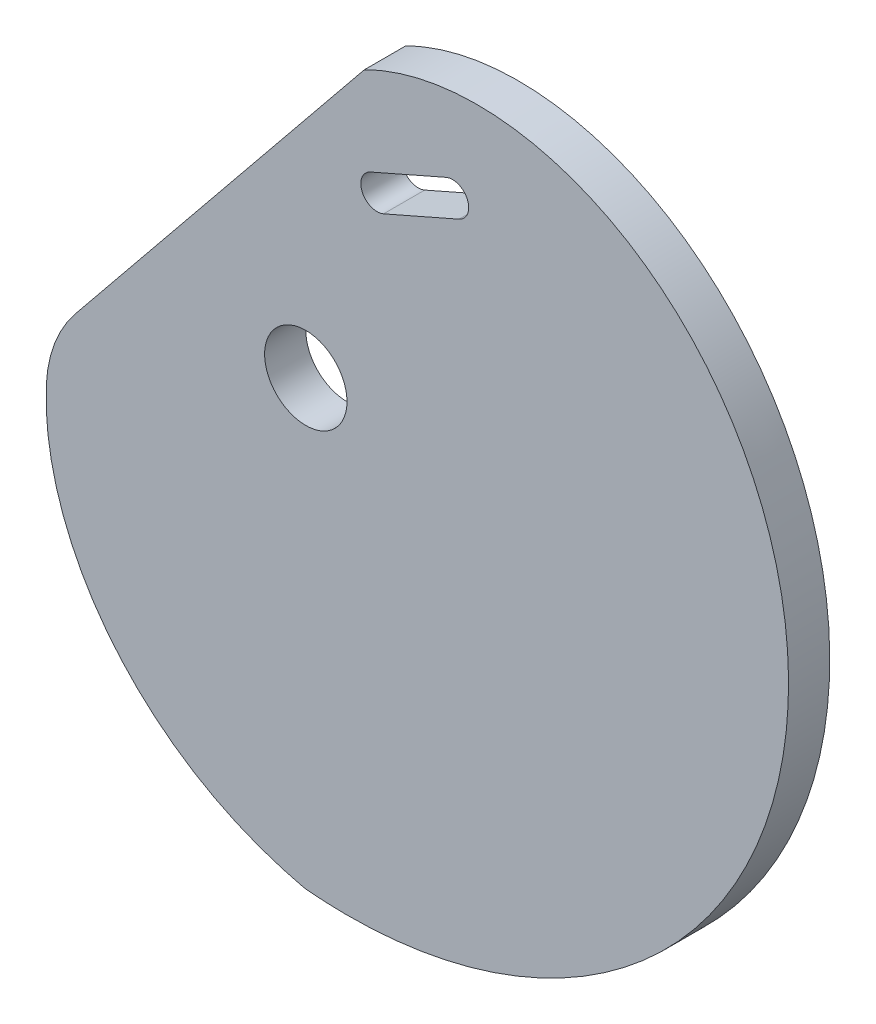
from build123d import *

# Parameters (mm, degrees)
SKETCH1_R               = 6.35
BOSS_EXTRUDE1_DEPTH     = 3.175
CUT_EXTRUDE1_DEPTH      = 102.208623711
CUT_EXTRUDE1_DEPTH_BACK = 102.208623711
FILLET1_R               = 20


with BuildPart() as part:
    # Sketch1 → Boss-Extrude1 (new, symmetric)
    with BuildSketch(Plane.XY):
        with BuildLine():
            add(Edge.make_bspline(
                [(0, -68.230921715), (0.393333706, -68.291733321), (1.194961176, -68.321276753), (2.388868431, -68.414811628), (3.58891617, -68.470136134), (4.791044831, -68.510535556), (5.995946289, -68.52954927), (7.203026535, -68.528713614), (8.412027616, -68.507423129), (9.62259203, -68.465654591), (10.83437986, -68.403235569), (12.047037443, -68.320041284), (13.260205927, -68.215942066), (14.473519127, -68.090817818), (15.686604264, -67.944554476), (16.899081946, -67.777045295), (18.110566359, -67.588190842), (19.320665416, -67.377899329), (20.528980925, -67.146086849), (21.73510877, -66.892677633), (22.938639087, -66.6176043), (24.139156466, -66.320808097), (25.336240146, -66.002239142), (26.529464226, -65.661856654), (27.718397887, -65.299629187), (28.90260561, -64.915534847), (30.081647414, -64.509561514), (31.255079097, -64.081707052), (32.42245248, -63.631979515), (33.58331567, -63.160397343), (34.737213315, -62.666989561), (35.883686879, -62.151795956), (37.022274916, -61.614867262), (38.152513354, -61.056265327), (39.273935784, -60.476063279), (40.386073758, -59.87434568), (41.488457085, -59.251208675), (42.580614147, -58.606760131), (43.662072205, -57.941119771), (44.732357722, -57.254419292), (45.790996682, -56.546802486), (46.837514925, -55.81842534), (47.871438475, -55.069456136), (48.89229388, -54.300075538), (49.899608554, -53.51047667), (50.892911122, -52.700865183), (51.871731772, -51.87145932), (52.835602603, -51.022489959), (53.784057989, -50.154200657), (54.71663493, -49.26684768), (55.632873421, -48.360700021), (56.532316811, -47.436039411), (57.414512174, -46.493160317), (58.279010671, -45.532369935), (59.125367928, -44.553988165), (59.953144401, -43.558347582), (60.761905749, -42.545793391), (61.55122321, -41.516683378), (62.320673971, -40.471387842), (63.069841543, -39.410289525), (63.798316132, -38.333783527), (64.505695017, -37.242277204), (65.191582915, -36.13619007), (65.85559236, -35.015953676), (66.497344063, -33.882011479), (67.11646729, -32.734818707), (67.71260022, -31.574842209), (68.285390316, -30.402560293), (68.834494677, -29.218462553), (69.359580408, -28.023049692), (69.860324965, -26.816833323), (70.336416512, -25.60033577), (70.787554269, -24.374089852), (71.213448854, -23.13863866), (71.613822626, -21.894535318), (71.988410015, -20.642342743), (72.336957858, -19.382633384), (72.659225719, -18.115988959), (72.954986211, -16.843000179), (73.224025309, -15.564266461), (73.466142659, -14.28039563), (73.681151874, -12.992003617), (73.868880836, -11.699714142), (74.029171977, -10.404158388), (74.161882563, -9.10597467), (74.266884966, -7.805808087), (74.344066927, -6.504310174), (74.393331816, -5.202138538), (74.414598879, -3.89995649), (74.407803478, -2.598432666), (74.372897323, -1.29824064), (74.309848696, -5.853e-05), (74.218642658, 1.295431404), (74.099281259, 2.587543173), (73.95178373, 3.875587471), (73.776186663, 5.158872107), (73.572544188, 6.43670243), (73.340928136, 7.708381771), (73.081428188, 8.973211889), (72.794152019, 10.230493418), (72.47922543, 11.479526328), (72.13679246, 12.719610386), (71.767015501, 13.950045625), (71.37007539, 15.170132817), (70.946171493, 16.379173951), (70.495521777, 17.576472716), (70.018362872, 18.761334989), (69.514950114, 19.933069325), (68.985557583, 21.090987453), (68.430478125, 22.234404772), (67.850023359, 23.362640855), (67.244523678, 24.47501995), (66.614328227, 25.570871489), (65.959804877, 26.649530597), (65.281340181, 27.710338599), (64.579339317, 28.752643533), (63.85422602, 29.775800665), (63.106442497, 30.779173), (62.33644933, 31.762131799), (61.544725366, 32.724057086), (60.731767601, 33.66433818), (59.898090995, 34.582374149), (59.044228508, 35.477574541), (58.170730235, 36.349359075), (57.278166357, 37.197160694), (56.367121668, 38.020410915), (55.438270074, 38.818621759), (54.492318121, 39.591335254), (53.529982536, 40.3381068), (52.551992493, 41.058512637), (51.559087829, 41.752148676), (50.552018856, 42.418631155), (49.531545735, 43.057596786), (48.498437965, 43.668703015), (47.453473832, 44.251628246), (46.397439863, 44.806072049), (45.331130274, 45.331755356), (44.255346411, 45.828420647), (43.17089619, 46.295832116), (42.078593533, 46.733775825), (40.979257798, 47.142059848), (39.873713209, 47.520514394), (38.762788284, 47.868991924), (37.647315256, 48.187367242), (36.528129497, 48.475537585), (35.406068937, 48.733422689), (34.281973488, 48.960964845), (33.156684455, 49.158128938), (32.031043959, 49.324902476), (30.905894352, 49.461295599), (29.78207764, 49.567341079), (28.66043489, 49.643094299), (27.541805663, 49.688633226), (26.427027423, 49.704058363), (25.316934962, 49.689492689), (24.212359828, 49.645081585), (23.114129743, 49.570992746), (22.023068037, 49.46741608), (20.939993076, 49.334563587), (19.865717696, 49.172669234), (18.801048645, 48.981988806), (17.746786017, 48.762799751), (16.703722704, 48.515401007), (15.672643843, 48.240112817), (14.654326272, 47.93727653), (13.64953799, 47.607254389), (12.659037622, 47.250429307), (11.683573889, 46.867204624), (10.723885088, 46.458003864), (9.780698574, 46.023270462), (8.85473025, 45.563467495), (7.946684063, 45.079077388), (7.057251515, 44.570601617), (6.187111156, 44.038560382), (5.336928158, 43.48349234), (4.507353656, 42.905954051), (3.699024971, 42.306520427), (2.912619563, 41.685826384), (2.149082762, 41.044776761), (1.408732666, 40.385653153), (0.69201842, 39.710962437), (-0.000702823, 39.023274092), (-0.669224606, 38.325164066), (-1.313490613, 37.619209289), (-1.933594741, 36.907981167), (-2.529780734, 36.194039342), (-3.102441662, 35.479925366), (-3.652119172, 34.768156406), (-4.179502537, 34.061218936), (-4.68542751, 33.361562432), (-5.170874981, 32.671593072), (-5.636969475, 31.993667421), (-6.084977486, 31.330086125), (-6.5163057, 30.68308757), (-6.932499191, 30.054841594), (-7.335239472, 29.447442991), (-7.726343211, 28.862905788), (-8.107759261, 28.30315506), (-8.481572996, 27.770028153), (-8.850055929, 27.265150233), (-9.21599154, 26.789707359), (-9.58007402, 26.342396401), (-9.943199031, 25.921274986), (-10.306211946, 25.524302901), (-10.669815304, 25.149428396), (-11.03457423, 24.794597749), (-11.400917427, 24.457759077), (-11.769139802, 24.136868148), (-12.139404915, 23.829894257), (-12.511747444, 23.534826559), (-12.886075425, 23.249680558), (-13.262172288, 22.972504592), (-13.639698706, 22.701386132), (-14.018194373, 22.4344578), (-14.397079826, 22.169903041), (-14.775658393, 21.905961469), (-15.153118349, 21.640933911), (-15.528535328, 21.37318718), (-15.900874865, 21.101158728), (-16.268995598, 20.823360748), (-16.631651048, 20.538385549), (-16.987497448, 20.244905703), (-17.335071725, 19.941700072), (-17.674482118, 19.629485326), (-18.005889299, 19.308945872), (-18.329486913, 18.98074786), (-18.645506177, 18.6455329), (-18.954213469, 18.303917657), (-19.255909475, 17.956492143), (-19.550927855, 17.603818409), (-19.839633983, 17.246429189), (-20.122423608, 16.884826615), (-20.39972148, 16.519480973), (-20.671979932, 16.15082951), (-20.93967742, 15.77927529), (-21.203317027, 15.405186109), (-21.463424922, 15.028893458), (-21.720548787, 14.650691546), (-21.975256201, 14.270836377), (-22.228133, 13.889544888), (-22.479781587, 13.506994147), (-22.730819224, 13.123320602), (-22.981876279, 12.738619403), (-23.233594452, 12.35294377), (-23.486624965, 11.966304432), (-23.741626724, 11.578669117), (-23.999264462, 11.189962103), (-24.260206854, 10.800063825), (-24.52512461, 10.408810538), (-24.794688561, 10.015994037), (-25.069567717, 9.621361426), (-25.350427363, 9.224614974), (-25.637926993, 8.8254119), (-25.932718851, 8.423364715), (-26.235444149, 8.018039723), (-26.546738212, 7.608962846), (-26.867193334, 7.195608336), (-27.197393741, 6.777566684), (-27.537037782, 6.353934602), (-27.885559202, 5.923803469), (-28.242374703, 5.486366009), (-28.606855737, 5.040842301), (-28.978345064, 4.586492757), (-29.356154138, 4.122615768), (-29.739565815, 3.648549546), (-30.127835637, 3.163672741), (-30.520193566, 2.667405334), (-30.915845631, 2.159209384), (-31.313975642, 1.638589743), (-31.713746908, 1.10509472), (-32.114303997, 0.558316687), (-32.514774496, -0.002107372), (-32.914270801, -0.576495363), (-33.311891916, -1.165119646), (-33.70672526, -1.768206653), (-34.097848491, -2.385936568), (-34.484331334, -3.01844306), (-34.865237414, -3.665813085), (-35.239626095, -4.328086735), (-35.606554319, -5.00525716), (-35.965078448, -5.697270543), (-36.314256102, -6.404026134), (-36.653147994, -7.125376348), (-36.98081976, -7.861126926), (-37.296343783, -8.611037148), (-37.598801011, -9.374820113), (-37.887282738, -10.15214308), (-38.160892488, -10.942627847), (-38.418747446, -11.745851279), (-38.659981522, -12.561345551), (-38.883742182, -13.388599746), (-39.089211497, -14.227059816), (-39.27554787, -15.076191303), (-39.442240692, -15.935443066), (-39.58900499, -16.804297383), (-39.715531283, -17.682274795), (-39.821534024, -18.56888584), (-39.906736403, -19.463633732), (-39.970874682, -20.366013757), (-40.01369729, -21.27551381), (-40.034965324, -22.191614638), (-40.034452659, -23.113790166), (-40.011946156, -24.041507803), (-39.967245835, -24.974228766), (-39.900165044, -25.911408403), (-39.810530622, -26.852496518), (-39.698183052, -27.796937709), (-39.56297661, -28.744171699), (-39.4047795, -29.693633681), (-39.223473982, -30.64475466), (-39.018956498, -31.596961802), (-38.791137779, -32.549678783), (-38.539942955, -33.502326148), (-38.265311644, -34.454321664), (-37.967198044, -35.405080681), (-37.645571006, -36.354016496), (-37.300414107, -37.300540716), (-36.931725709, -38.244063627), (-36.539519007, -39.18399456), (-36.123822074, -40.119742265), (-35.684677893, -41.050715279), (-35.222144381, -41.976322302), (-34.736294403, -42.89597257), (-34.227215775, -43.809076229), (-33.695011264, -44.715044715), (-33.139798572, -45.613291121), (-32.561710315, -46.503230581), (-31.960893988, -47.384280643), (-31.337511928, -48.255861642), (-30.69174126, -49.117397078), (-30.023773839, -49.96831399), (-29.333816181, -50.808043326), (-28.622089382, -51.636020317), (-27.888829033, -52.451684847), (-27.134285123, -53.25448182), (-26.358721931, -54.04386153), (-25.562417912, -54.819280022), (-24.745665571, -55.580199454), (-23.908771332, -56.326088459), (-23.052055394, -57.0564225), (-22.175851579, -57.770684224), (-21.280507172, -58.468363812), (-20.366382752, -59.148959324), (-19.433852012, -59.811977048), (-18.483301577, -60.456931829), (-17.515130802, -61.083347415), (-16.529751575, -61.690756781), (-15.527588097, -62.278702456), (-14.50907667, -62.846736843), (-13.474665463, -63.39442255), (-12.424814268, -63.921332635), (-11.359994294, -64.427051169), (-10.280687768, -64.911172569), (-9.187388219, -65.373305515), (-8.080598179, -65.813059652), (-6.960836498, -66.230096831), (-5.828609627, -66.623940268), (-4.684517934, -66.994691537), (-3.528855652, -67.340343195), (-2.3631095, -67.666856553), (-1.184338477, -67.950378607), (-0.400093515, -68.169065005), (0, -68.230921715)],
                knots=[0, 0, 0, 0, 0.003319606, 0.00664483, 0.00997572, 0.013312315, 0.016654652, 0.020002764, 0.023356679, 0.026716422, 0.030082012, 0.033453467, 0.036830797, 0.040214011, 0.043603114, 0.046998106, 0.050398984, 0.05380574, 0.057218364, 0.060636841, 0.064061153, 0.067491279, 0.070927192, 0.074368865, 0.077816264, 0.081269354, 0.084728096, 0.088192446, 0.09166236, 0.095137787, 0.098618675, 0.102104968, 0.105596607, 0.10909353, 0.112595671, 0.116102963, 0.119615332, 0.123132706, 0.126655005, 0.130182149, 0.133714056, 0.137250637, 0.140791804, 0.144337465, 0.147887524, 0.151441884, 0.155000443, 0.158563099, 0.162129745, 0.165700272, 0.169274569, 0.172852522, 0.176434014, 0.180018926, 0.183607137, 0.187198521, 0.190792953, 0.194390304, 0.197990441, 0.201593231, 0.205198539, 0.208806224, 0.212416148, 0.216028167, 0.219642135, 0.223257906, 0.226875331, 0.230494258, 0.234114533, 0.237736001, 0.241358506, 0.244981886, 0.248605983, 0.252230632, 0.255855669, 0.259480928, 0.263106241, 0.266731437, 0.270356345, 0.273980794, 0.277604607, 0.281227611, 0.284849627, 0.288470478, 0.292089983, 0.295707963, 0.299324234, 0.302938615, 0.306550921, 0.310160967, 0.313768569, 0.317373538, 0.320975689, 0.324574833, 0.328170782, 0.331763348, 0.335352341, 0.338937573, 0.342518853, 0.346095993, 0.349668803, 0.353237093, 0.356800674, 0.360359359, 0.363912958, 0.367461284, 0.37100415, 0.37454137, 0.37807276, 0.381598135, 0.385117313, 0.388630113, 0.392136355, 0.395635862, 0.399128458, 0.402613969, 0.406092224, 0.409563054, 0.413026294, 0.416481778, 0.419929348, 0.423368847, 0.426800121, 0.43022302, 0.4336374, 0.437043112, 0.440439966, 0.443827754, 0.447206268, 0.450575308, 0.453934675, 0.457284173, 0.460623612, 0.463952804, 0.467271567, 0.470579721, 0.473877092, 0.477163509, 0.480438807, 0.483702825, 0.486955407, 0.490196401, 0.493425661, 0.496643048, 0.499848424, 0.50304166, 0.506222633, 0.509391223, 0.512547319, 0.515690814, 0.518821608, 0.521939609, 0.52504473, 0.528136891, 0.531216019, 0.53428205, 0.537334925, 0.540374595, 0.543401017, 0.546414157, 0.549413988, 0.552400493, 0.555373664, 0.5583335, 0.56128001, 0.564213213, 0.567133138, 0.570039821, 0.572933311, 0.575813665, 0.578680954, 0.581535256, 0.58437666, 0.58720527, 0.590021199, 0.59282457, 0.59561552, 0.598394199, 0.601160164, 0.603910525, 0.606641733, 0.609350191, 0.612032273, 0.614684334, 0.617302722, 0.619883791, 0.622423916, 0.624919509, 0.627367038, 0.629763043, 0.632104166, 0.634387177, 0.636609005, 0.638766786, 0.640857908, 0.642880081, 0.644831406, 0.646710483, 0.648516525, 0.650249514, 0.65191136, 0.653508519, 0.655048349, 0.65653798, 0.657984241, 0.659393583, 0.66077201, 0.662125022, 0.663457568, 0.664774018, 0.666078151, 0.667373165, 0.668661696, 0.669945853, 0.671227263, 0.672507127, 0.673786273, 0.67506522, 0.676344239, 0.677623416, 0.678902717, 0.68018205, 0.681461324, 0.682740438, 0.684019262, 0.685297659, 0.686575488, 0.687852615, 0.689128915, 0.690404281, 0.691678632, 0.692951916, 0.694224122, 0.695495279, 0.696765474, 0.698034846, 0.699303605, 0.70057203, 0.70184048, 0.703109399, 0.704379325, 0.705650892, 0.706924838, 0.708202013, 0.709483377, 0.710770009, 0.712063109, 0.713363997, 0.714674119, 0.715995039, 0.717328447, 0.718676146, 0.720040056, 0.721422204, 0.722824718, 0.724249822, 0.725699824, 0.727177002, 0.72868281, 0.730218172, 0.731783831, 0.733380363, 0.735008197, 0.736667628, 0.738358831, 0.740081872, 0.741836722, 0.743623264, 0.745441305, 0.747290584, 0.749170776, 0.751081502, 0.753022336, 0.754992805, 0.756992401, 0.759020578, 0.761076761, 0.763160347, 0.76527071, 0.767407202, 0.769569155, 0.771755887, 0.7739667, 0.776200882, 0.778457713, 0.780736462, 0.783036392, 0.785356757, 0.787696808, 0.790055792, 0.792432952, 0.794827532, 0.797238799, 0.799666426, 0.802110394, 0.804570687, 0.807047284, 0.809540165, 0.812049305, 0.814574675, 0.817116246, 0.819673984, 0.822247852, 0.824837811, 0.82744382, 0.830065834, 0.832703806, 0.835357687, 0.838027424, 0.840712962, 0.843414244, 0.84613121, 0.848863798, 0.851611942, 0.854375576, 0.857154631, 0.859949033, 0.862758708, 0.865583582, 0.868423573, 0.871278601, 0.874148584, 0.877033434, 0.879933066, 0.882847387, 0.885776307, 0.888719732, 0.891677564, 0.894649707, 0.897636058, 0.900636516, 0.903650977, 0.906679333, 0.909721476, 0.912777297, 0.915846682, 0.918929518, 0.922025687, 0.925135072, 0.928257554, 0.931393009, 0.934541315, 0.937702347, 0.940875975, 0.944062073, 0.947260508, 0.950471149, 0.95369386, 0.956928506, 0.960174949, 0.96343305, 0.966702667, 0.969983657, 0.973275876, 0.976579178, 0.979893415, 0.983218438, 0.986554095, 0.989900235, 0.993256703, 0.996623344, 1, 1, 1, 1], degree=3))
        make_face()
        Circle(SKETCH1_R, mode=Mode.SUBTRACT)
        with BuildLine():
            Line((9.976048944, 32.474429955), (21.605937727, 37.576947657))
            ThreePointArc((21.605937727, 37.576947657), (24.899718531, 36.29203209), (23.614802964, 32.998251286))
            Line((23.614802964, 32.998251286), (11.984914181, 27.895733584))
            ThreePointArc((11.984914181, 27.895733584), (8.691133377, 29.180649151), (9.976048944, 32.474429955))
        make_face(mode=Mode.SUBTRACT)
    extrude(amount=BOSS_EXTRUDE1_DEPTH, both=True)

    # Sketch2 → Cut-Extrude1 (cut, two sides)
    with BuildSketch(Plane.XY) as cut_extrude1_sk:
        Polygon((-35.700141367, -3.650772794), (-5.287048439, 46.63912797), (7.47895927, 46.63912797), (9.017790377, 45.641265466), (-41.200196706, -16.19692185), align=None)
    extrude(amount=CUT_EXTRUDE1_DEPTH, mode=Mode.SUBTRACT)
    extrude(cut_extrude1_sk.sketch, amount=-CUT_EXTRUDE1_DEPTH_BACK, mode=Mode.SUBTRACT)

    # Fillet1
    fillet1_edges = [part.edges().sort_by_distance(p)[0] for p in [
        (-38.861787447, -13.317415956, -1.5875),
    ]]
    fillet(fillet1_edges, radius=FILLET1_R)


solid = part.part
